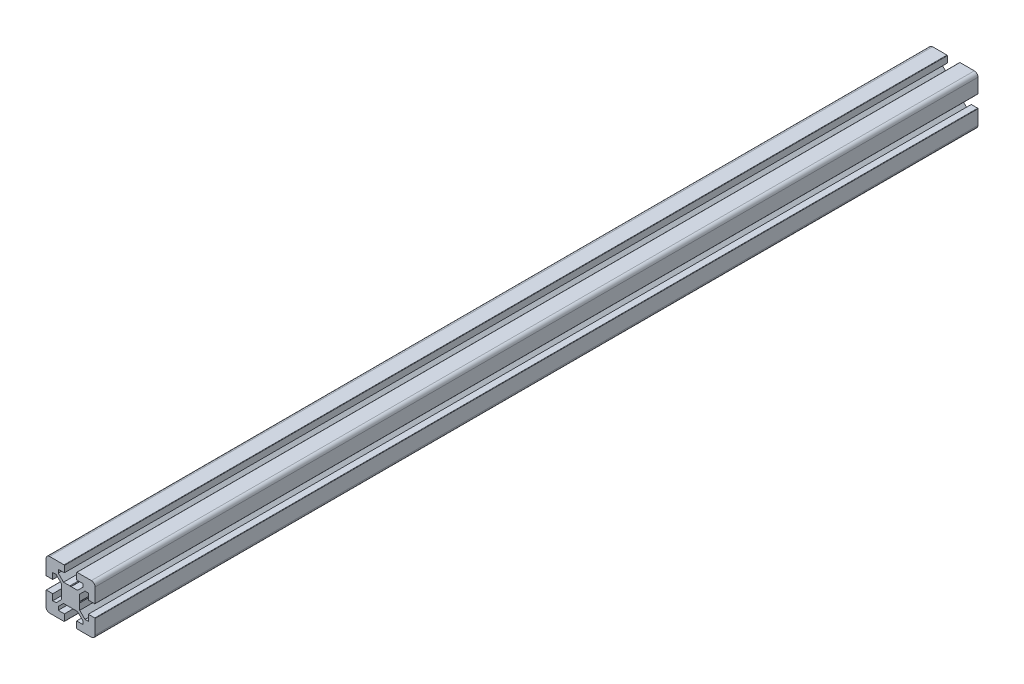
from build123d import *

# Parameters (mm, degrees)
EXTRUDE_1_DEPTH = 720


with BuildPart() as part:
    # Model → ﾎﾞｽ - 押し出し1 (new body)
    with BuildSketch(Plane.XY):
        with BuildLine():
            Line((69.700000053, 55.000000195), (64.500000711, 55.000000195))
            Line((64.500000711, 55.000000195), (64.500000711, 60.000002187))
            Line((64.500000711, 60.000002187), (61.76777021, 60.000002187))
            Line((61.76777021, 60.000002187), (57.500000584, 55.732232559))
            Line((57.500000584, 55.732232559), (57.500000584, 50.519614724))
            Line((57.500000584, 50.519614724), (57.199999339, 50.000000177))
            Line((57.199999339, 50.000000177), (57.500000584, 49.48038563))
            Line((57.500000584, 49.48038563), (57.500000584, 44.267767795))
            Line((57.500000584, 44.267767795), (61.76777021, 39.999998167))
            Line((61.76777021, 39.999998167), (64.500000711, 39.999998167))
            Line((64.500000711, 39.999998167), (64.500000711, 45.000000159))
            Line((64.500000711, 45.000000159), (69.700000053, 45.000000159))
            ThreePointArc((69.700000053, 45.000000159), (69.9121326, 44.912131981), (70.000000778, 44.699999434))
            Line((70.000000778, 44.699999434), (70.000000778, 33.000000332))
            ThreePointArc((70.000000778, 33.000000332), (69.121321121, 30.878679988), (67.000000778, 30.000000332))
            Line((67.000000778, 30.000000332), (55.300001675, 30.000000332))
            ThreePointArc((55.300001675, 30.000000332), (55.087869129, 30.08786851), (55.000000951, 30.300001056))
            Line((55.000000951, 30.300001056), (55.000000951, 35.500000399))
            Line((55.000000951, 35.500000399), (60.000002943, 35.500000399))
            Line((60.000002943, 35.500000399), (60.000002943, 38.232230899))
            Line((60.000002943, 38.232230899), (55.732233316, 42.500000527))
            Line((55.732233316, 42.500000527), (50.519615481, 42.500000527))
            Line((50.519615481, 42.500000527), (50.000000936, 42.800001775))
            Line((50.000000936, 42.800001775), (49.480386391, 42.500000527))
            Line((49.480386391, 42.500000527), (44.267768556, 42.500000527))
            Line((44.267768556, 42.500000527), (39.999998929, 38.232230899))
            Line((39.999998929, 38.232230899), (39.999998929, 35.500000399))
            Line((39.999998929, 35.500000399), (45.000000921, 35.500000399))
            Line((45.000000921, 35.500000399), (45.000000921, 30.300001056))
            ThreePointArc((45.000000921, 30.300001056), (44.912132743, 30.08786851), (44.700000197, 30.000000332))
            Line((44.700000197, 30.000000332), (33.000001094, 30.000000332))
            ThreePointArc((33.000001094, 30.000000332), (30.87868075, 30.878679988), (30.000001094, 33.000000332))
            Line((30.000001094, 33.000000332), (30.000001094, 44.699999434))
            ThreePointArc((30.000001094, 44.699999434), (30.087869272, 44.912131981), (30.300001819, 45.000000159))
            Line((30.300001819, 45.000000159), (35.500001161, 45.000000159))
            Line((35.500001161, 45.000000159), (35.500001161, 39.999998167))
            Line((35.500001161, 39.999998167), (38.232231661, 39.999998167))
            Line((38.232231661, 39.999998167), (42.499994889, 44.267761396))
            Line((42.499994889, 44.267761396), (42.499994889, 49.48038563))
            Line((42.499994889, 49.48038563), (42.799996134, 50.000000177))
            Line((42.799996134, 50.000000177), (42.499994889, 50.519614724))
            Line((42.499994889, 50.519614724), (42.499994889, 55.732238958))
            Line((42.499994889, 55.732238958), (38.232231661, 60.000002187))
            Line((38.232231661, 60.000002187), (35.500001161, 60.000002187))
            Line((35.500001161, 60.000002187), (35.500001161, 55.000000195))
            Line((35.500001161, 55.000000195), (30.300001819, 55.000000195))
            ThreePointArc((30.300001819, 55.000000195), (30.087869272, 55.087868373), (30.000001094, 55.30000092))
            Line((30.000001094, 55.30000092), (30.000001094, 67.000000023))
            ThreePointArc((30.000001094, 67.000000023), (30.87868075, 69.121320366), (33.000001094, 70.000000023))
            Line((33.000001094, 70.000000023), (44.700000197, 70.000000023))
            ThreePointArc((44.700000197, 70.000000023), (44.912132743, 69.912131845), (45.000000921, 69.699999298))
            Line((45.000000921, 69.699999298), (45.000000921, 64.499999956))
            Line((45.000000921, 64.499999956), (39.999998929, 64.499999956))
            Line((39.999998929, 64.499999956), (39.999998929, 61.767769455))
            Line((39.999998929, 61.767769455), (44.267768556, 57.499999827))
            Line((44.267768556, 57.499999827), (49.480386391, 57.499999827))
            Line((49.480386391, 57.499999827), (50.000000936, 57.199998579))
            Line((50.000000936, 57.199998579), (50.519615481, 57.499999827))
            Line((50.519615481, 57.499999827), (55.732233316, 57.499999827))
            Line((55.732233316, 57.499999827), (60.000002943, 61.767769455))
            Line((60.000002943, 61.767769455), (60.000002943, 64.499999956))
            Line((60.000002943, 64.499999956), (55.000000951, 64.499999956))
            Line((55.000000951, 64.499999956), (55.000000951, 69.699999298))
            ThreePointArc((55.000000951, 69.699999298), (55.087869129, 69.912131845), (55.300001675, 70.000000023))
            Line((55.300001675, 70.000000023), (67.000000778, 70.000000023))
            ThreePointArc((67.000000778, 70.000000023), (69.121321121, 69.121320366), (70.000000778, 67.000000023))
            Line((70.000000778, 67.000000023), (70.000000778, 55.30000092))
            ThreePointArc((70.000000778, 55.30000092), (69.9121326, 55.087868373), (69.700000053, 55.000000195))
        make_face()
    extrude(amount=-EXTRUDE_1_DEPTH)


solid = part.part
